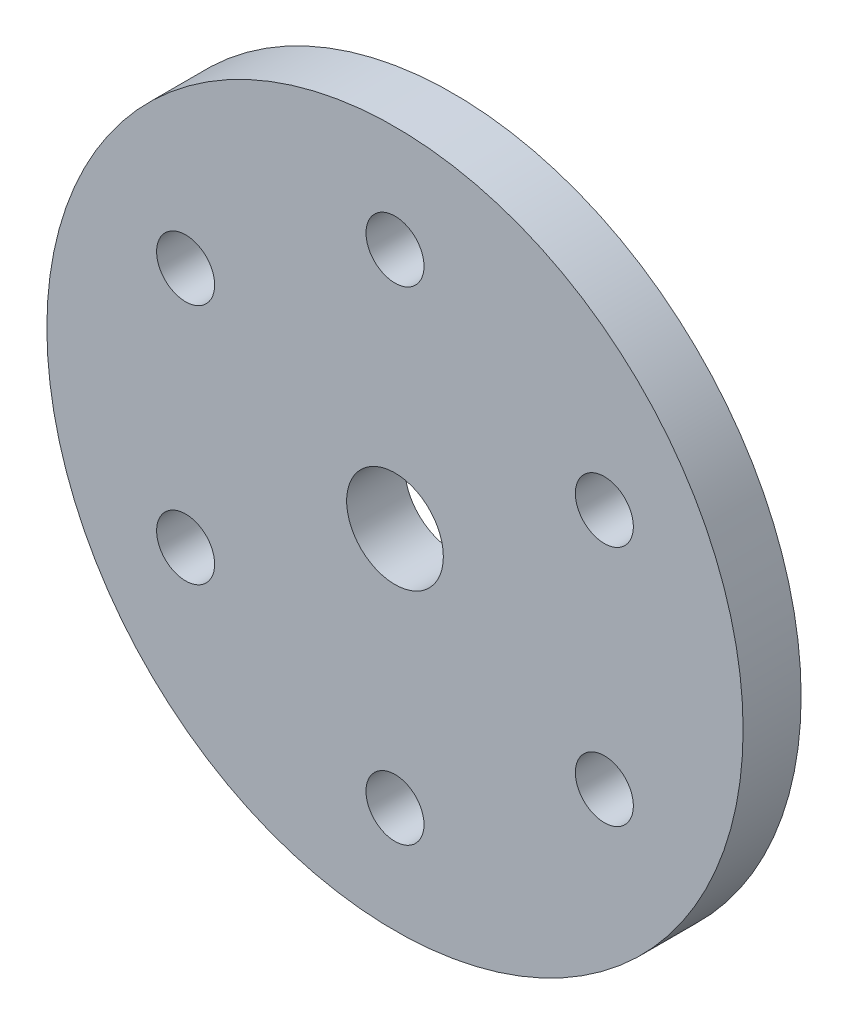
from build123d import *

# Parameters (mm, degrees)
SKETCH1_R           = 18
SKETCH1_R_2         = 1.5
SKETCH1_R_3         = 2.5
BOSS_EXTRUDE1_DEPTH = 3


with BuildPart() as part:
    # Sketch1 → Boss-Extrude1 (new body)
    with BuildSketch(Plane.XY):
        Circle(SKETCH1_R)
        with Locations((0, 12.5)):
            Circle(SKETCH1_R_2, mode=Mode.SUBTRACT)
        with Locations((10.825317547, 6.25)):
            Circle(SKETCH1_R_2, mode=Mode.SUBTRACT)
        with Locations((10.825317547, -6.25)):
            Circle(SKETCH1_R_2, mode=Mode.SUBTRACT)
        with Locations((0, -12.5)):
            Circle(SKETCH1_R_2, mode=Mode.SUBTRACT)
        with Locations((-10.825317547, -6.25)):
            Circle(SKETCH1_R_2, mode=Mode.SUBTRACT)
        with Locations((-10.825317547, 6.25)):
            Circle(SKETCH1_R_2, mode=Mode.SUBTRACT)
        Circle(SKETCH1_R_3, mode=Mode.SUBTRACT)
    extrude(amount=BOSS_EXTRUDE1_DEPTH)


solid = part.part
